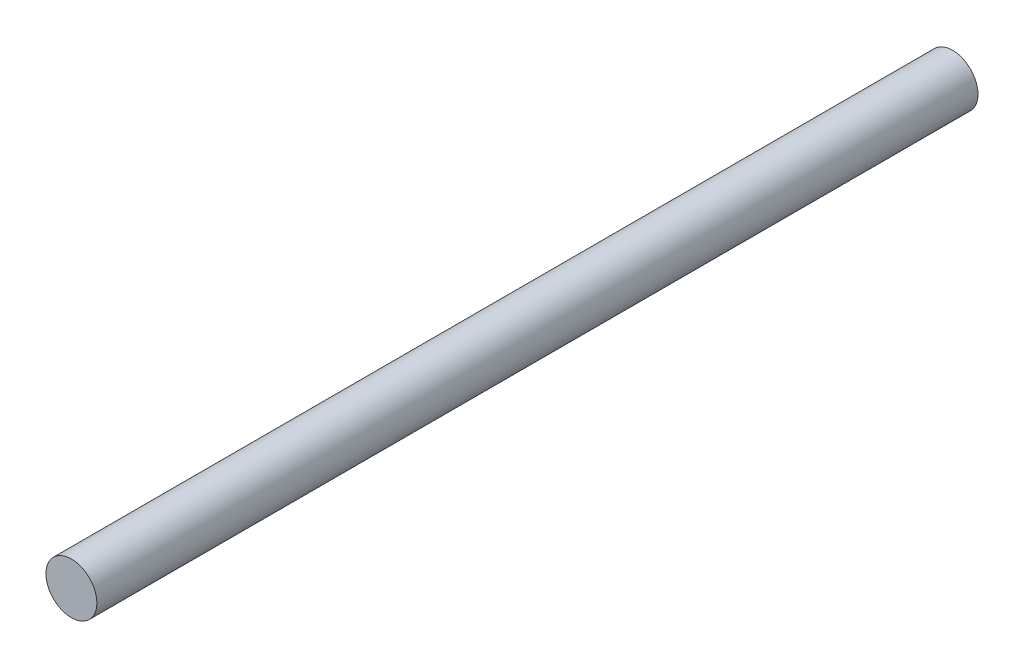
from build123d import *

# Parameters (mm, degrees)
SKETCH1_R           = 1.3
BOSS_EXTRUDE1_DEPTH = 45


with BuildPart() as part:
    # Sketch1 → Boss-Extrude1 (new body)
    with BuildSketch(Plane.XY):
        Circle(SKETCH1_R)
    extrude(amount=BOSS_EXTRUDE1_DEPTH)


solid = part.part
